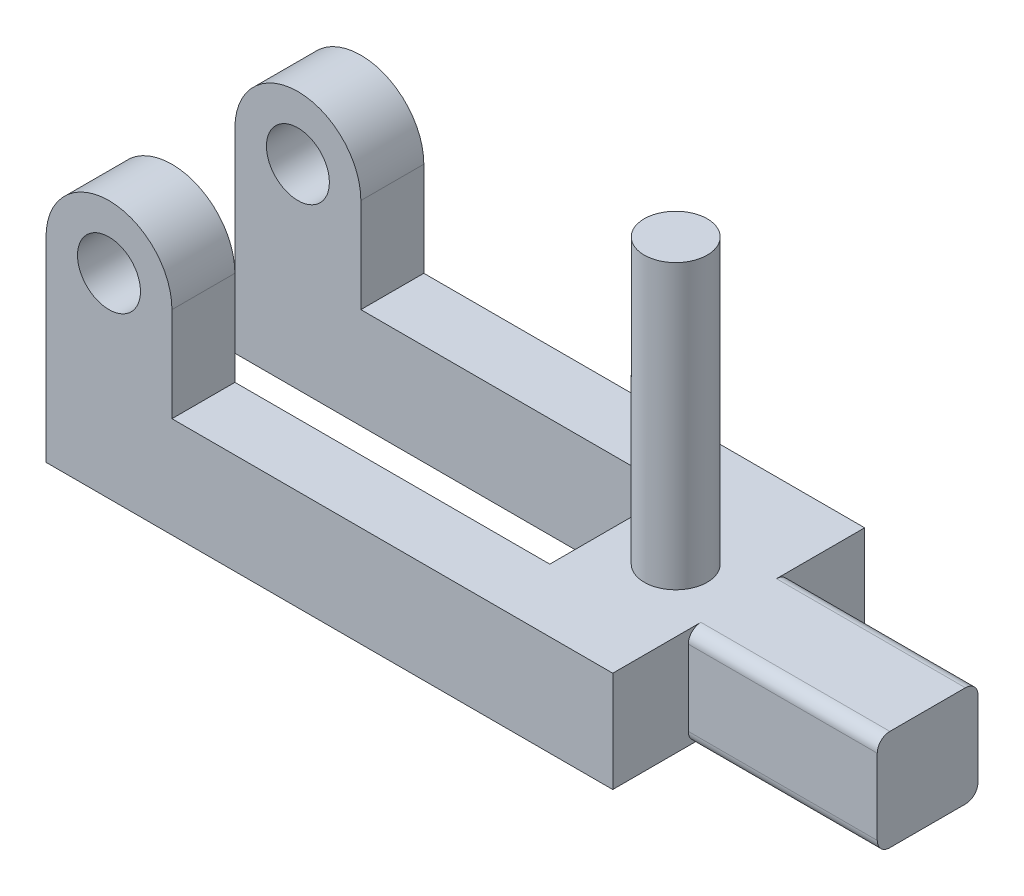
from build123d import *

# Parameters (mm, degrees)
BOSS_EXTRUDE1_DEPTH = 16
FILLET1_R           = 2
SKETCH3_R           = 5
BOSS_EXTRUDE2_DEPTH = 10
LPATTERN1_COUNT     = 2
LPATTERN1_PITCH     = 30
SKETCH4_R           = 5
BOSS_EXTRUDE3_DEPTH = 45


with BuildPart() as part:
    # Sketch2 → Boss-Extrude1 (new body)
    with BuildSketch(Plane(origin=(0, 0, 0), x_dir=(1, 0, 0), z_dir=(0, 1, 0))):
        Polygon((0, 30), (0, 40), (90, 40), (90, 28), (120, 28), (120, 12), (90, 12), (90, 0), (0, 0), (0, 10), (70, 10), (70, 30), align=None)
    extrude(amount=BOSS_EXTRUDE1_DEPTH)

    # Fillet1
    fillet1_edges = [part.edges().sort_by_distance(p)[0] for p in [
        (105, 16, -12),
        (105, 0, -28),
        (105, 0, -12),
        (105, 16, -28),
    ]]
    fillet(fillet1_edges, radius=FILLET1_R)

    # Sketch3 → Boss-Extrude2 (add)
    with BuildSketch(Plane.XY):
        with BuildLine():
            Line((0, 16), (20, 16))
            Line((20, 16), (20, 31))
            ThreePointArc((20, 31), (10, 41), (0, 31))
            Line((0, 31), (0, 16))
        make_face()
        with Locations((10, 31)):
            Circle(SKETCH3_R, mode=Mode.SUBTRACT)
    boss_extrude2 = extrude(amount=-BOSS_EXTRUDE2_DEPTH)

    # LPattern1: Boss-Extrude2 ×2
    with Locations(*[(0, 0, -i * LPATTERN1_PITCH) for i in range(1, LPATTERN1_COUNT)]):
        add(boss_extrude2)

    # Sketch4 → Boss-Extrude3 (add)
    with BuildSketch(Plane(origin=(0, 16, 0), x_dir=(1, 0, 0), z_dir=(0, 1, 0))):
        with Locations((80, 20)):
            Circle(SKETCH4_R)
    extrude(amount=BOSS_EXTRUDE3_DEPTH)


solid = part.part
